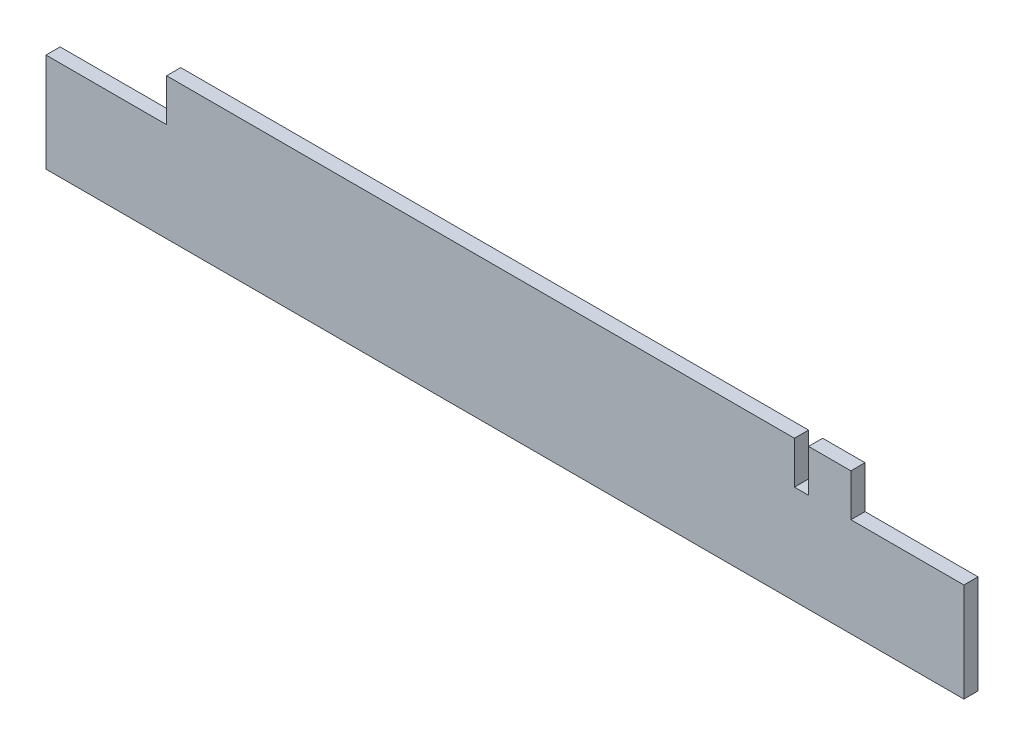
from build123d import *

# Parameters (mm, degrees)
BOSS_EXTRU_1_DEPTH      = 10
ESQUISSE2_W             = 10
ESQUISSE2_H             = 30
ENL_V_MAT_EXTRU_1_DEPTH = 11


with BuildPart() as part:
    # Esquisse1 → Boss.-Extru.1 (new body)
    with BuildSketch(Plane.XY):
        Polygon((-325, -149.452554745), (-325, -219.452554745), (325, -219.452554745), (325, -149.452554745), (245, -149.452554745), (245, -119.452554745), (-239.598540146, -119.452554745), (-239.598540146, -149.452554745), align=None)
    extrude(amount=BOSS_EXTRU_1_DEPTH)

    # Esquisse2 → Enlèv. mat.-Extru.1 (cut, through all)
    with BuildSketch(Plane(origin=(0, 0, 0), x_dir=(-1, 0, 0), z_dir=(0, 0, -1))):
        with Locations((-210, -134.452554745)):
            Rectangle(ESQUISSE2_W, ESQUISSE2_H)
    extrude(amount=-ENL_V_MAT_EXTRU_1_DEPTH, mode=Mode.SUBTRACT)


solid = part.part
